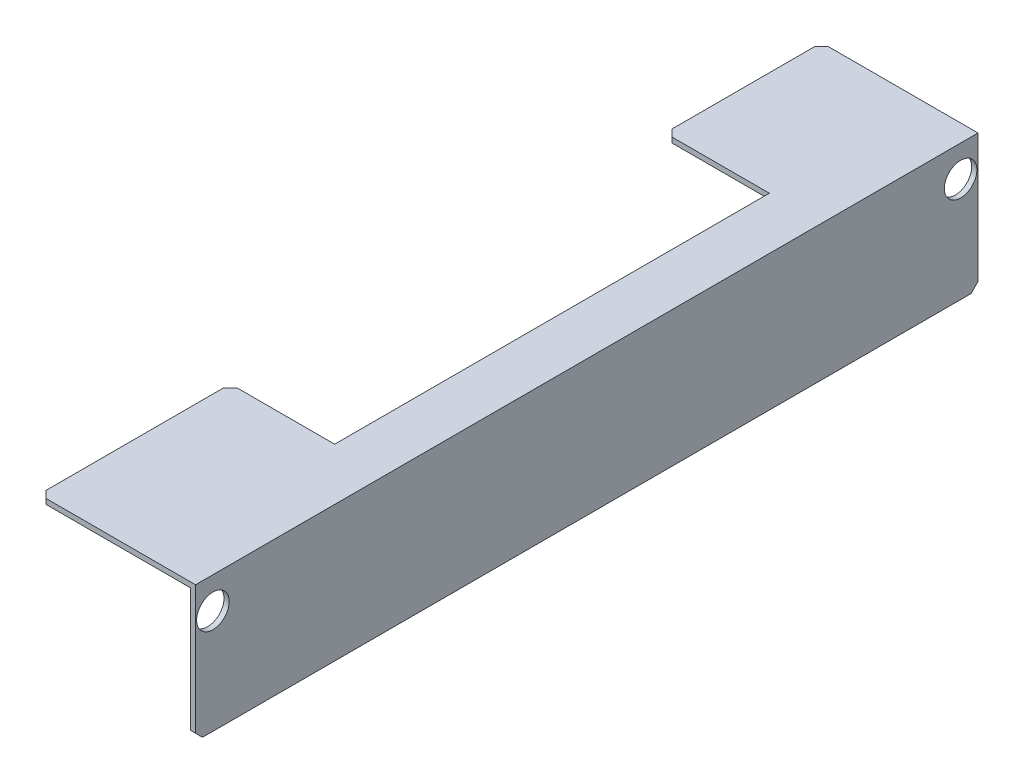
from build123d import *

# Parameters (mm, degrees)
BOSS_EXTRUDE1_DEPTH = 225
SKETCH3_W           = 30
SKETCH3_H           = 125
CUT_EXTRUDE1_DEPTH  = 225
SKETCH4_R           = 4.687343619
CUT_EXTRUDE2_DEPTH  = 225
CHAMFER1_SIZE       = 2


with BuildPart() as part:
    # Sketch1 → Boss-Extrude1 (new body)
    with BuildSketch(Plane.XY):
        Polygon((-39.755639098, 20.306390977), (5.244360902, 20.306390977), (5.244360902, -18.693609023), (3.744360902, -18.693609023), (3.744360902, 18.806390977), (-39.755639098, 18.806390977), align=None)
    extrude(amount=BOSS_EXTRUDE1_DEPTH)

    # Sketch3 → Cut-Extrude1 (cut)
    with BuildSketch(Plane(origin=(0, 20.306390977, 0), x_dir=(1, 0, 0), z_dir=(0, 1, 0))):
        with Locations((-24.755639098, -107.5)):
            Rectangle(SKETCH3_W, SKETCH3_H)
    extrude(amount=-CUT_EXTRUDE1_DEPTH, mode=Mode.SUBTRACT)

    # Sketch4 → Cut-Extrude2 (cut)
    with BuildSketch(Plane.ZY.offset(-3.744360902)):
        with Locations((5, 11.306390977)):
            Circle(SKETCH4_R)
        with Locations((220, 11.306390977)):
            Circle(SKETCH4_R)
    extrude(amount=-CUT_EXTRUDE2_DEPTH, mode=Mode.SUBTRACT)

    # Chamfer1
    chamfer1_edges = [part.edges().sort_by_distance(p)[0] for p in [
        (4.494360902, -18.693609023, 225),
        (-39.755639098, 19.556390977, 170),
        (-39.755639098, 19.556390977, 45),
        (-39.755639098, 19.556390977, 225),
        (4.494360902, -18.693609023, 0),
        (-39.755639098, 19.556390977, 0),
    ]]
    chamfer(chamfer1_edges, length=CHAMFER1_SIZE)


solid = part.part
